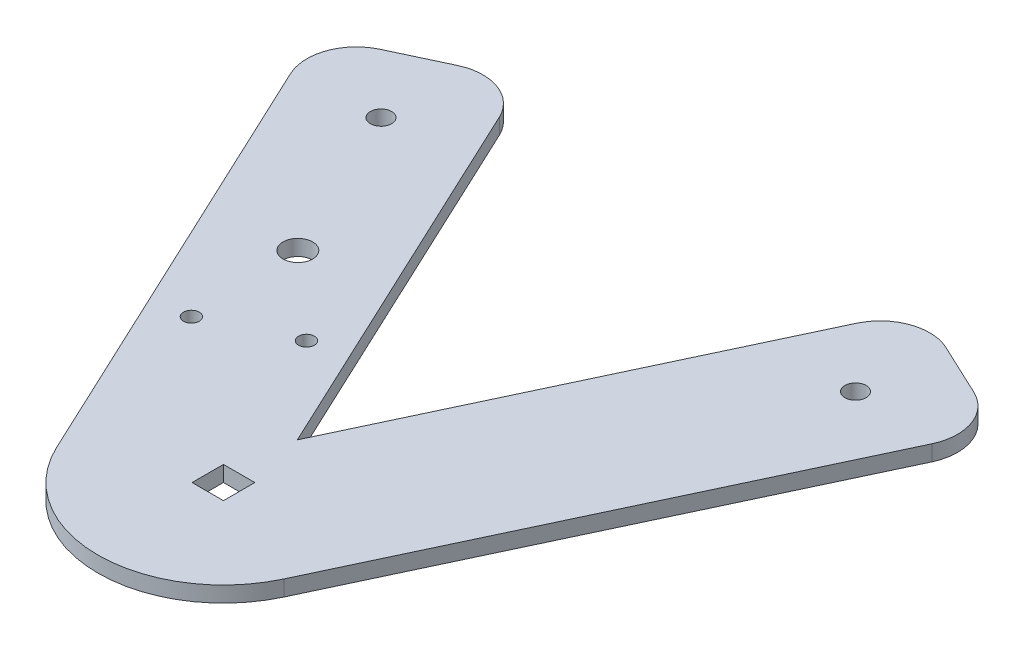
from build123d import *

# Parameters (mm, degrees)
SKETCH1_R           = 2.15
SKETCH1_R_2         = 3
SKETCH1_R_3         = 1.6
SKETCH1_W           = 6.35
SKETCH1_H           = 6.35
BOSS_EXTRUDE1_DEPTH = 3.175
FILLET1_R           = 10


with BuildPart() as part:
    # Sketch1 → Boss-Extrude1 (new body)
    with BuildSketch(Plane(origin=(0, 0, 0), x_dir=(1, 0, 0), z_dir=(0, 1, 0))):
        with BuildLine():
            Line((-69.108920632, 87.491689248), (-22.994598309, -10.789274703))
            ThreePointArc((-22.994598309, -10.789274703), (0, -25.4), (22.994598309, -10.789274703))
            Line((22.994598309, -10.789274703), (69.108920632, 87.491689248))
            Line((69.108920632, 87.491689248), (40.365672746, 100.978282626))
            Line((40.365672746, 100.978282626), (0, 14.949104962))
            Line((0, 14.949104962), (-40.365672746, 100.978282626))
            Line((-40.365672746, 100.978282626), (-69.108920632, 87.491689248))
        make_face()
        with Locations((47.994, 79.863361994)):
            Circle(SKETCH1_R, mode=Mode.SUBTRACT)
        with Locations((-47.994, 79.863361994)):
            Circle(SKETCH1_R, mode=Mode.SUBTRACT)
        with Locations((-33.126889189, 48.177891883)):
            Circle(SKETCH1_R_2, mode=Mode.SUBTRACT)
        with Locations((-32.297900068, 25.811951773)):
            Circle(SKETCH1_R_3, mode=Mode.SUBTRACT)
        with Locations((-16.455165013, 33.245507178)):
            Circle(SKETCH1_R_3, mode=Mode.SUBTRACT)
        Rectangle(SKETCH1_W, SKETCH1_H, mode=Mode.SUBTRACT)
    extrude(amount=BOSS_EXTRUDE1_DEPTH)

    # Fillet1
    fillet1_edges = [part.edges().sort_by_distance(p)[0] for p in [
        (-40.365672746, 1.5875, -100.978282626),
        (40.365672746, 1.5875, -100.978282626),
        (69.108920632, 1.5875, -87.491689248),
        (-69.108920632, 1.5875, -87.491689248),
    ]]
    fillet(fillet1_edges, radius=FILLET1_R)


solid = part.part
